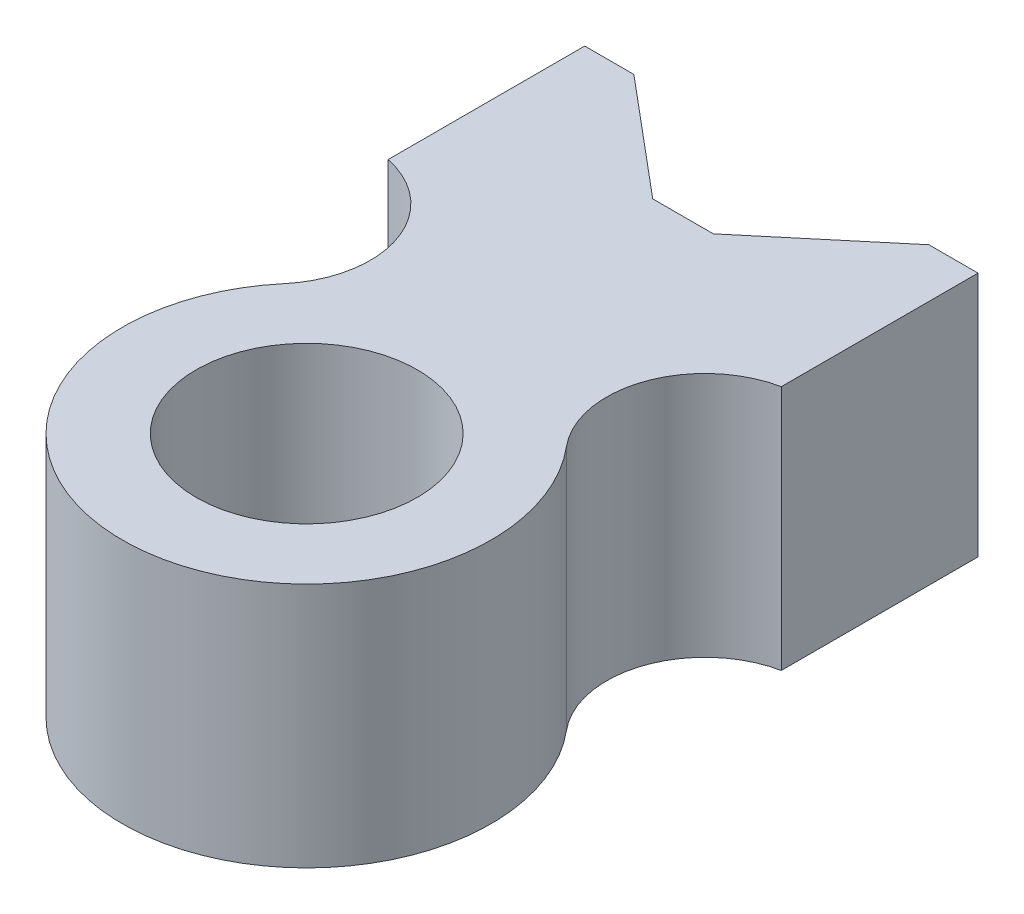
from build123d import *

# Parameters (mm, degrees)
CROQUIS2_R              = 22.5
SALIENTE_EXTRUIR1_DEPTH = 50


with BuildPart() as part:
    # Croquis2 → Saliente-Extruir1 (new body)
    with BuildSketch(Plane(origin=(0, 0, 0), x_dir=(1, 0, 0), z_dir=(0, 1, 0))):
        with BuildLine():
            Line((-6.164928148, 76.54643814), (6.164928148, 76.54643814))
            Line((6.164928148, 76.54643814), (30, 96.54643814))
            Line((30, 96.54643814), (40, 96.54643814))
            Line((40, 96.54643814), (40, 56.54643814))
            ThreePointArc((40, 56.54643814), (25.155667723, 43.525085879), (28.726666617, 24.104535363))
            ThreePointArc((28.726666617, 24.104535363), (0, -37.5), (-28.726666617, 24.104535363))
            ThreePointArc((-28.726666617, 24.104535363), (-25.155667723, 43.525085879), (-40, 56.54643814))
            Line((-40, 56.54643814), (-40, 96.54643814))
            Line((-40, 96.54643814), (-30, 96.54643814))
            Line((-30, 96.54643814), (-6.164928148, 76.54643814))
        make_face()
        Circle(CROQUIS2_R, mode=Mode.SUBTRACT)
    extrude(amount=SALIENTE_EXTRUIR1_DEPTH)


solid = part.part
